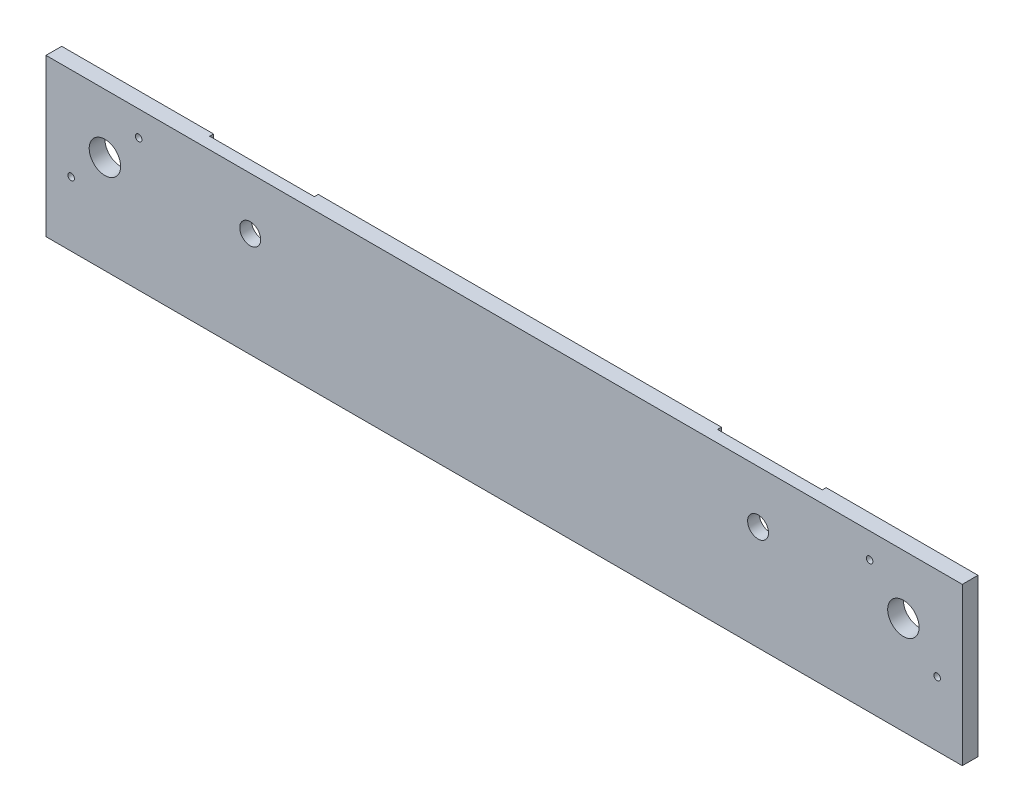
from build123d import *

# Parameters (mm, degrees)
CROQUIS1_W              = 350
CROQUIS1_H              = 60
SALIENTE_EXTRUIR1_DEPTH = 6
CROQUIS2_R              = 6
CROQUIS2_R_2            = 1.25
CORTAR_EXTRUIR1_DEPTH   = 7
CORTAR_EXTRUIR4_DEPTH   = 1.5
CROQUIS4_R              = 4
CORTAR_EXTRUIR5_DEPTH   = 7


with BuildPart() as part:
    # Croquis1 → Saliente-Extruir1 (new body)
    with BuildSketch(Plane.XY):
        with Locations((-175, -30)):
            Rectangle(CROQUIS1_W, CROQUIS1_H)
    extrude(amount=SALIENTE_EXTRUIR1_DEPTH)

    # Croquis2 → Cortar-Extruir1 (cut, through all)
    with BuildSketch(Plane.XY.offset(6)):
        with Locations((-327.5, -22.5)):
            Circle(CROQUIS2_R)
        with Locations((-22.5, -22.5)):
            Circle(CROQUIS2_R)
        with Locations((-314.595301243, -9.595301243)):
            Circle(CROQUIS2_R_2)
        with Locations((-340.404698757, -35.404698757)):
            Circle(CROQUIS2_R_2)
        with Locations((-35.404698757, -9.595301243)):
            Circle(CROQUIS2_R_2)
        with Locations((-9.595301243, -35.404698757)):
            Circle(CROQUIS2_R_2)
    extrude(amount=-CORTAR_EXTRUIR1_DEPTH, mode=Mode.SUBTRACT)

    # Croquis3 → Cortar-Extruir4 (cut)
    with BuildSketch(Plane.XY):
        with BuildLine():
            Line((-98, 0), (-58, 0))
            Line((-58, 0), (-58, -36))
            ThreePointArc((-58, -36), (-59.171572875, -38.828427125), (-62, -40))
            Line((-62, -40), (-94, -40))
            ThreePointArc((-94, -40), (-96.828427125, -38.828427125), (-98, -36))
            Line((-98, -36), (-98, 0))
        make_face()
        with BuildLine():
            Line((-292, 0), (-252, 0))
            Line((-252, 0), (-252, -36))
            ThreePointArc((-252, -36), (-253.171572875, -38.828427125), (-256, -40))
            Line((-256, -40), (-288, -40))
            ThreePointArc((-288, -40), (-290.828427125, -38.828427125), (-292, -36))
            Line((-292, -36), (-292, 0))
        make_face()
    extrude(amount=CORTAR_EXTRUIR4_DEPTH, mode=Mode.SUBTRACT)

    # Croquis4 → Cortar-Extruir5 (cut, through all)
    with BuildSketch(Plane.XY.offset(6)):
        with Locations((-272, -20)):
            Circle(CROQUIS4_R)
        with Locations((-78, -20)):
            Circle(CROQUIS4_R)
    extrude(amount=-CORTAR_EXTRUIR5_DEPTH, mode=Mode.SUBTRACT)


solid = part.part
